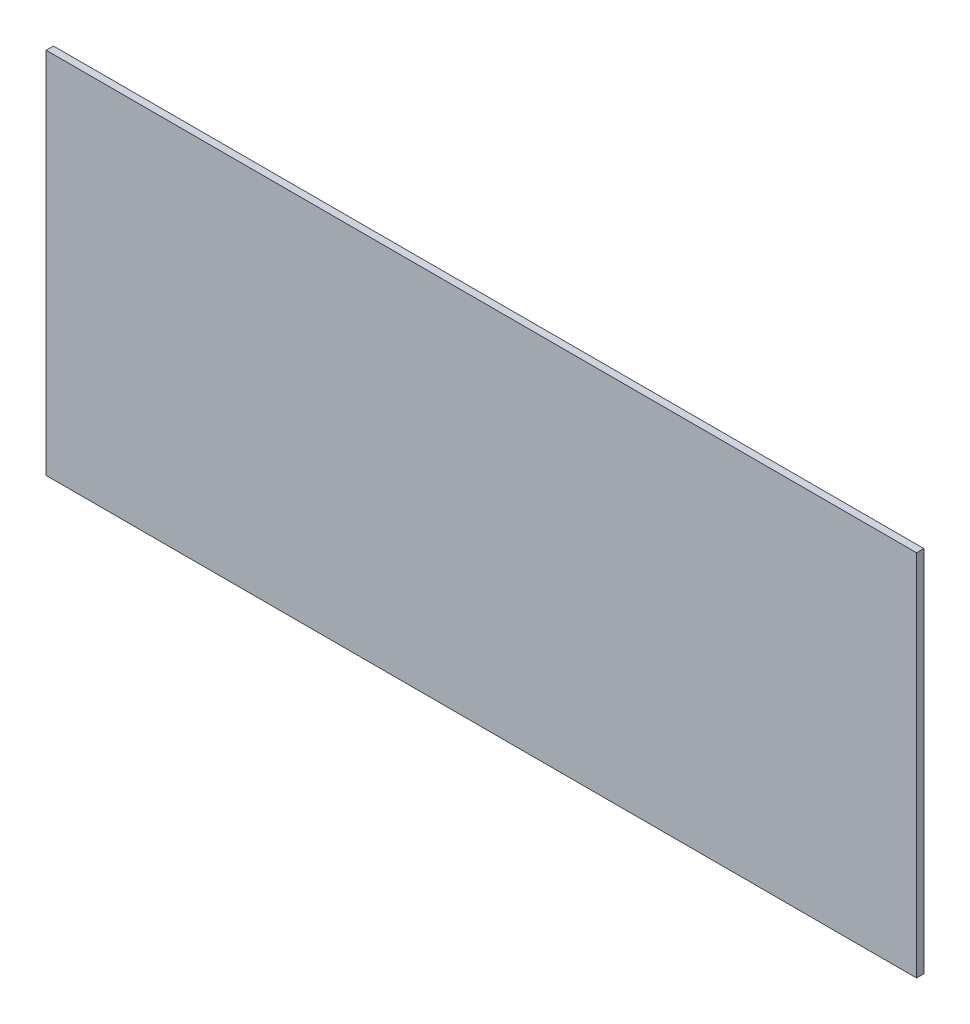
from build123d import *

# Parameters (mm, degrees)
SKETCH1_W           = 536.5
SKETCH1_H           = 227
BOSS_EXTRUDE1_DEPTH = 2.2479


with BuildPart() as part:
    # Sketch1 → Boss-Extrude1 (new body, symmetric)
    with BuildSketch(Plane.XY):
        Rectangle(SKETCH1_W, SKETCH1_H)
    extrude(amount=BOSS_EXTRUDE1_DEPTH, both=True)


solid = part.part
